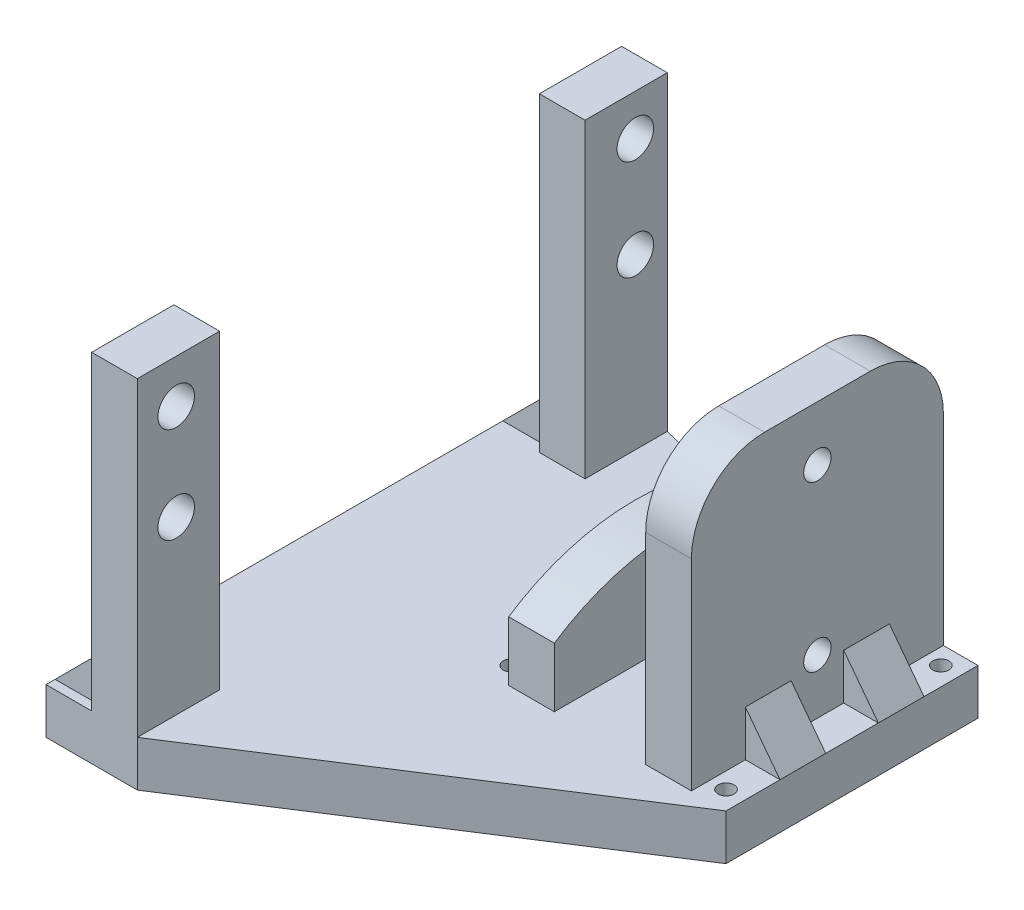
from build123d import *

# Parameters (mm, degrees)
SKETCH1_W            = 27.578431842
SKETCH1_H            = 27.578431842
SKETCH1_R            = 0.875
BOSS_EXTRUDE1_DEPTH  = 5
SKETCH2_W            = 5
SKETCH2_H            = 27.578431842
BOSS_EXTRUDE2_DEPTH  = 30
CUT_EXTRUDE2_DEPTH   = 10
SKETCH5_R            = 1.5
CUT_EXTRUDE3_DEPTH   = 24
FILLET1_R            = 8
FILLET2_R            = 8
SKETCH6_W            = 10
SKETCH6_H            = 10
CUT_EXTRUDE5_DEPTH   = 7
SKETCH7_R            = 3
CUT_EXTRUDE6_DEPTH   = 7
SKETCH8_W            = 3.789215921
SKETCH8_H            = 5
BOSS_EXTRUDE3_DEPTH  = 5
CUT_EXTRUDE7_DEPTH   = 25
SKETCH10_W           = 27.578431842
SKETCH10_H           = 5
BOSS_EXTRUDE4_DEPTH  = 11.61
BOSS_EXTRUDE5_DEPTH  = 5
BOSS_EXTRUDE9_DEPTH  = 5
SKETCH18_W           = 5
SKETCH18_H           = 7
BOSS_EXTRUDE10_DEPTH = 5
CUT_EXTRUDE9_DEPTH   = 59
SKETCH20_R           = 2
CUT_EXTRUDE10_DEPTH  = 10
BOSS_EXTRUDE11_DEPTH = 5


with BuildPart() as part:
    # Sketch1 → Boss-Extrude1 (new body)
    with BuildSketch(Plane(origin=(0, 0, 0), x_dir=(1, 0, 0), z_dir=(0, 1, 0))):
        with Locations((13.789215921, 13.789215921)):
            Rectangle(SKETCH1_W, SKETCH1_H)
        with Locations((2.032931996, 2.032931996)):
            Circle(SKETCH1_R, mode=Mode.SUBTRACT)
        with Locations((25.545499846, 25.545499846)):
            Circle(SKETCH1_R, mode=Mode.SUBTRACT)
        with Locations((2.032931996, 25.545499846)):
            Circle(SKETCH1_R, mode=Mode.SUBTRACT)
        with Locations((25.545513651, 2.032918191)):
            Circle(SKETCH1_R, mode=Mode.SUBTRACT)
    extrude(amount=BOSS_EXTRUDE1_DEPTH)

    # Sketch2 → Boss-Extrude2 (add)
    with BuildSketch(Plane(origin=(0, 5, 0), x_dir=(1, 0, 0), z_dir=(0, 1, 0))):
        with Locations((21.289215921, 13.789215921)):
            Rectangle(SKETCH2_W, SKETCH2_H)
        with Locations((6.289215921, 13.789215921)):
            Rectangle(SKETCH2_W, SKETCH2_H)
    extrude(amount=BOSS_EXTRUDE2_DEPTH)

    # Sketch4 → Cut-Extrude2 (cut)
    with BuildSketch(Plane.ZY.offset(-3.789215921)):
        with BuildLine():
            Line((-27.578431842, 11.509370995), (-27.578431842, 35))
            Line((-27.578431842, 35), (0, 35))
            Line((0, 35), (0, 11.509370995))
            ThreePointArc((0, 11.509370995), (-13.789215921, 15.656133254), (-27.578431842, 11.509370995))
        make_face()
    extrude(amount=-CUT_EXTRUDE2_DEPTH, mode=Mode.SUBTRACT)

    # Sketch5 → Cut-Extrude3 (cut)
    with BuildSketch(Plane(origin=(23.789215921, 0, 0), x_dir=(0, 0, -1), z_dir=(1, 0, 0))):
        with Locations((13.789215921, 29)):
            Circle(SKETCH5_R)
        with Locations((13.789215921, 11)):
            Circle(SKETCH5_R)
    extrude(amount=-CUT_EXTRUDE3_DEPTH, mode=Mode.SUBTRACT)

    # Fillet1
    fillet1_edges = [part.edges().sort_by_distance(p)[0] for p in [
        (21.289215921, 35, 0),
    ]]
    fillet(fillet1_edges, radius=FILLET1_R)

    # Fillet2
    fillet2_edges = [part.edges().sort_by_distance(p)[0] for p in [
        (21.289215921, 35, -27.578431842),
    ]]
    fillet(fillet2_edges, radius=FILLET2_R)

    # Sketch6 → Cut-Extrude5 (cut)
    with BuildSketch(Plane(origin=(0, 5, 0), x_dir=(1, 0, 0), z_dir=(0, 1, 0))):
        with Locations((13.789215921, 22.578431842)):
            Rectangle(SKETCH6_W, SKETCH6_H)
    extrude(amount=-CUT_EXTRUDE5_DEPTH, mode=Mode.SUBTRACT)

    # Sketch7 → Cut-Extrude6 (cut)
    with BuildSketch(Plane.XZ):
        with Locations((13.789215921, -13.789215921)):
            Circle(SKETCH7_R)
    extrude(amount=-CUT_EXTRUDE6_DEPTH, mode=Mode.SUBTRACT)

    # Sketch8 → Boss-Extrude3 (add)
    with BuildSketch(Plane(origin=(0, 5, 0), x_dir=(1, 0, 0), z_dir=(0, 1, 0))):
        with Locations((1.894607961, 19.170499846)):
            Rectangle(SKETCH8_W, SKETCH8_H)
        with Locations((25.683823882, 19.170499846)):
            Rectangle(SKETCH8_W, SKETCH8_H)
        with Locations((25.683823882, 8.407918191)):
            Rectangle(SKETCH8_W, SKETCH8_H)
        with Locations((1.894607961, 8.407918191)):
            Rectangle(SKETCH8_W, SKETCH8_H)
    extrude(amount=BOSS_EXTRUDE3_DEPTH)

    # Sketch9 → Cut-Extrude7 (cut)
    with BuildSketch(Plane.XY.offset(-5.907918191)):
        Polygon((0, 5), (3.789215921, 10), (0, 10), align=None)
        Polygon((23.789215921, 10), (27.578431842, 5), (27.578431842, 10), align=None)
    extrude(amount=-CUT_EXTRUDE7_DEPTH, mode=Mode.SUBTRACT)

    # Sketch10 → Boss-Extrude4 (add)
    with BuildSketch(Plane.ZY):
        with Locations((-13.789215921, 2.5)):
            Rectangle(SKETCH10_W, SKETCH10_H)
    extrude(amount=BOSS_EXTRUDE4_DEPTH)

    # Sketch11 → Boss-Extrude5 (add)
    with BuildSketch(Plane.ZY.offset(11.61)):
        Polygon((-32.758431842, 9.017116473), (-32.758431842, 0), (-27.578431842, 0), (0, 0), (25.24, 0), (25.24, 9.017116473), (25.24, 39), (16.24, 39), (16.24, 5), (0, 5), (-23.758431842, 5), (-23.758431842, 39), (-32.758431842, 39), align=None)
    extrude(amount=BOSS_EXTRUDE5_DEPTH)

    # Sketch17 → Boss-Extrude9 (add)
    with BuildSketch(Plane.ZY.offset(16.61)):
        Polygon((-23.758431842, 5), (-32.758431842, 5), (-32.758431842, 0), (25.24, 0), (25.24, 5), align=None)
    extrude(amount=BOSS_EXTRUDE9_DEPTH)

    # Sketch18 → Boss-Extrude10 (add)
    with BuildSketch(Plane(origin=(0, 5, 0), x_dir=(1, 0, 0), z_dir=(0, 1, 0))):
        with Locations((-19.11, 28.258431842)):
            Rectangle(SKETCH18_W, SKETCH18_H)
        with Locations((-19.11, -20.74)):
            Rectangle(SKETCH18_W, SKETCH18_H)
    extrude(amount=BOSS_EXTRUDE10_DEPTH)

    # Sketch19 → Cut-Extrude9 (cut)
    with BuildSketch(Plane.XY.offset(24.24)):
        Polygon((-21.61, 5), (-21.61, 10), (-16.61, 10), align=None)
    extrude(amount=-CUT_EXTRUDE9_DEPTH, mode=Mode.SUBTRACT)

    # Sketch20 → Cut-Extrude10 (cut)
    with BuildSketch(Plane(origin=(-11.61, 0, 0), x_dir=(0, 0, -1), z_dir=(1, 0, 0))):
        with Locations((-20.988693629, 34.251254581)):
            Circle(SKETCH20_R)
        with Locations((-20.989186345, 23.751254593)):
            Circle(SKETCH20_R)
        with Locations((29.260801868, 23.498896595)):
            Circle(SKETCH20_R)
        with Locations((29.261318047, 34.498896583)):
            Circle(SKETCH20_R)
    extrude(amount=-CUT_EXTRUDE10_DEPTH, mode=Mode.SUBTRACT)

    # Sketch21 → Boss-Extrude11 (add)
    with BuildSketch(Plane(origin=(0, 5, 0), x_dir=(1, 0, 0), z_dir=(0, 1, 0))):
        Polygon((-11.61, -25.24), (27.578431842, 0), (-11.61, 0), align=None)
        Polygon((-11.61, 32.758431842), (8.789215921, 27.578431842), (-11.61, 27.578431842), align=None)
    extrude(amount=-BOSS_EXTRUDE11_DEPTH)


solid = part.part
